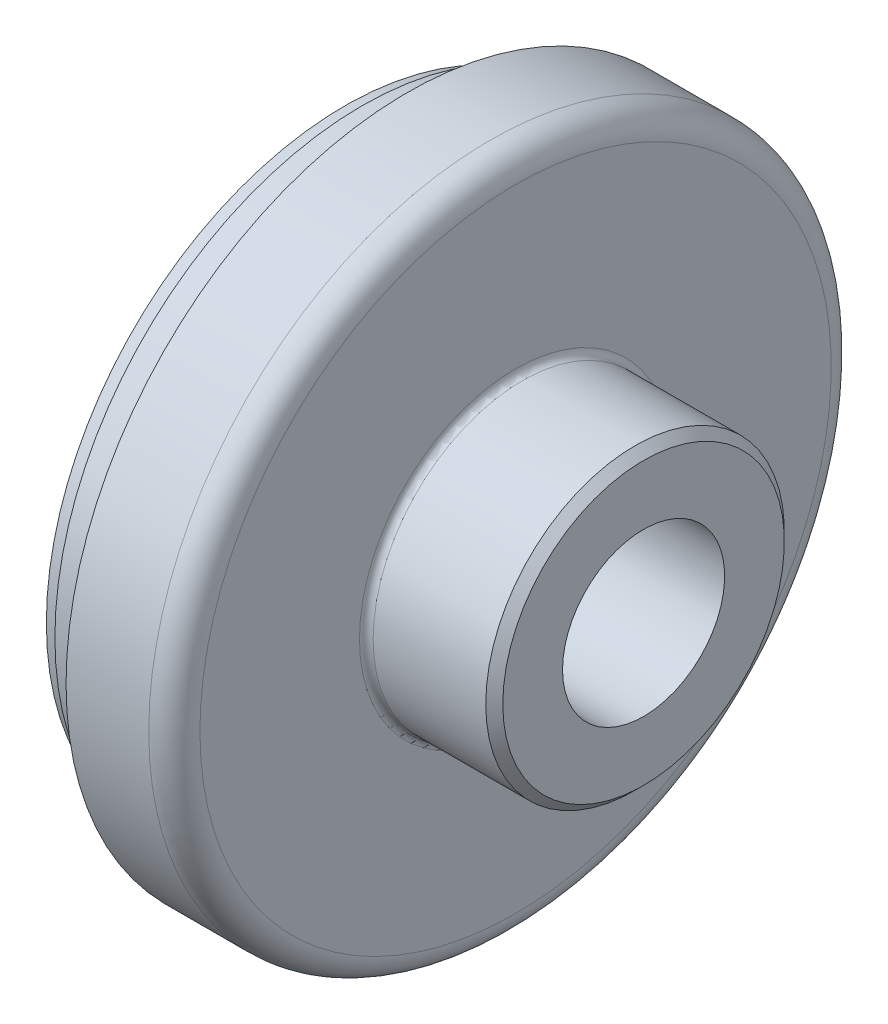
from build123d import *


with BuildPart() as part:
    # Sketch1 → Base-Revolve (revolve)
    with BuildSketch(Plane.XY):
        with BuildLine():
            Line((0, 9.5), (35, 9.5))
            Line((35, 9.5), (35, 16.5))
            Line((35, 16.5), (34, 17.5))
            Line((34, 17.5), (20.8, 17.5))
            ThreePointArc((20.8, 17.5), (20.234314575, 17.734314575), (20, 18.3))
            Line((20, 18.3), (20, 37))
            ThreePointArc((20, 37), (19.121320344, 39.121320344), (17, 40))
            Line((17, 40), (7.309401077, 40))
            Line((7.309401077, 40), (5, 36))
            Line((5, 36), (2, 36))
            Line((2, 36), (2, 35))
            Line((2, 35), (0, 35))
            Line((0, 35), (0, 9.5))
        make_face()
    revolve(axis=Axis((-31.276903974, 0, 0), (1, 0, 0)))


solid = part.part
